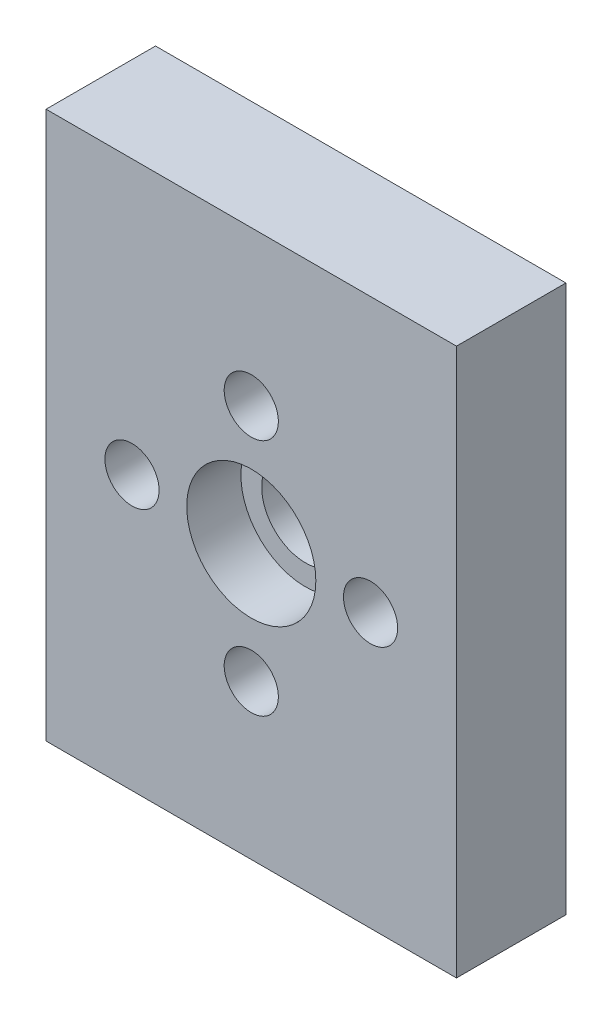
from build123d import *

# Parameters (mm, degrees)
SKETCH1_W           = 19.05
SKETCH1_H           = 25.4
BOSS_EXTRUDE1_DEPTH = 5.08
SKETCH2_R           = 2.9972
CUT_EXTRUDE1_DEPTH  = 2.5146
SKETCH3_R           = 2.032
CUT_EXTRUDE2_DEPTH  = 3.5654
SKETCH4_R           = 1.2573
CUT_EXTRUDE4_DEPTH  = 6.08


with BuildPart() as part:
    # Sketch1 → Boss-Extrude1 (new body)
    with BuildSketch(Plane.XY):
        Rectangle(SKETCH1_W, SKETCH1_H)
    extrude(amount=BOSS_EXTRUDE1_DEPTH)

    # Sketch2 → Cut-Extrude1 (cut)
    with BuildSketch(Plane.XY.offset(5.08)):
        Circle(SKETCH2_R)
    extrude(amount=-CUT_EXTRUDE1_DEPTH, mode=Mode.SUBTRACT)

    # Sketch3 → Cut-Extrude2 (cut, through all)
    with BuildSketch(Plane.XY.offset(2.5654)):
        Circle(SKETCH3_R)
    extrude(amount=-CUT_EXTRUDE2_DEPTH, mode=Mode.SUBTRACT)

    # Sketch4 → Cut-Extrude4 (cut, through all)
    with BuildSketch(Plane.XY.offset(5.08)):
        with Locations((0, 5.5372)):
            Circle(SKETCH4_R)
        with Locations((5.5372, 0)):
            Circle(SKETCH4_R)
        with Locations((0, -5.5372)):
            Circle(SKETCH4_R)
        with Locations((-5.5372, 0)):
            Circle(SKETCH4_R)
    extrude(amount=-CUT_EXTRUDE4_DEPTH, mode=Mode.SUBTRACT)


solid = part.part
